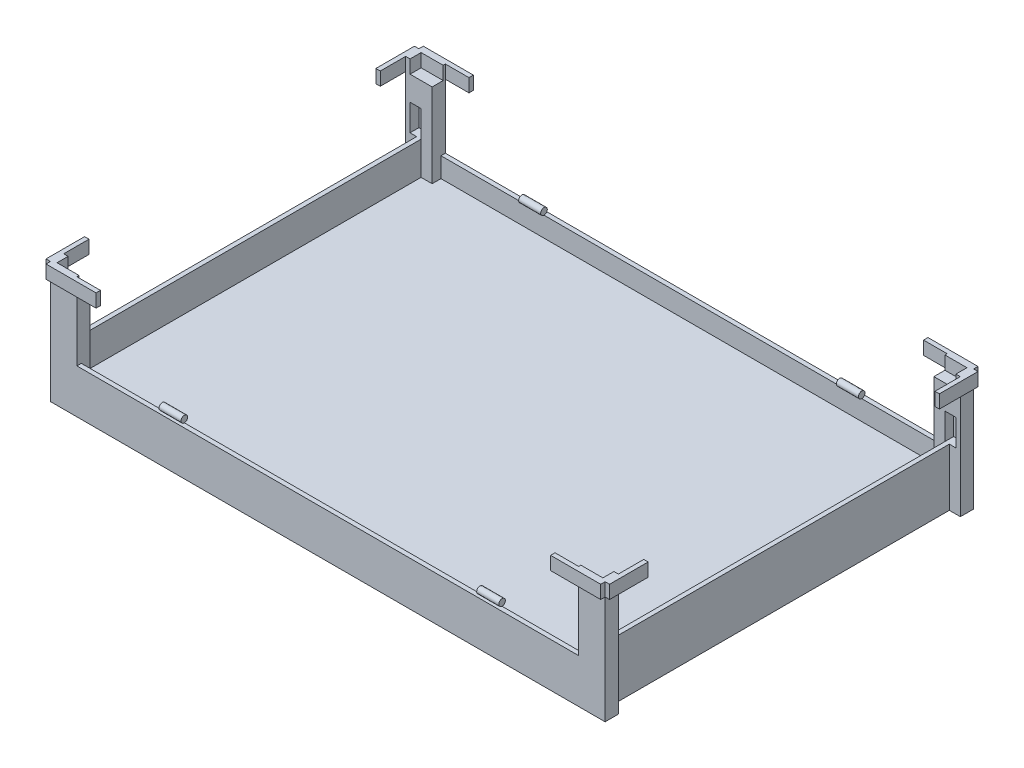
from build123d import *

# Parameters (mm, degrees)
SCHIZZO1_W                    = 1207
SCHIZZO1_H                    = 835
ESTRUSIONE_ESTRUSIONE2_DEPTH  = 100
SVUOTA1_T                     = -10
ESTRUSIONE_ESTRUSIONE3_REACH  = 837
SCHIZZO6_W                    = 1207
SCHIZZO6_H                    = 10
SCHIZZO12_W                   = 10
SCHIZZO12_H                   = 835
ESTRUSIONE_ESTRUSIONE10_DEPTH = 30
SCHIZZO7_W                    = 60
SCHIZZO7_H                    = 275
ESTRUSIONE_ESTRUSIONE4_DEPTH  = 10
SCHIZZO8_W                    = 20
SCHIZZO8_H                    = 145
ESTRUSIONE_ESTRUSIONE5_DEPTH  = 10
SCHIZZO9_W                    = 5
SCHIZZO9_H                    = 30
ESTRUSIONE_ESTRUSIONE6_DEPTH  = 75
SCHIZZO10_W                   = 5
SCHIZZO10_H                   = 30
ESTRUSIONE_ESTRUSIONE7_DEPTH  = 65
SCHIZZO11_W                   = 5
SCHIZZO11_H                   = 20
ESTRUSIONE_ESTRUSIONE8_DEPTH  = 25
SCHIZZO8_3_W                  = 20
SCHIZZO8_3_H                  = 130
ESTRUSIONE_ESTRUSIONE9_DEPTH  = 25
SCHIZZO14_W                   = 87.5
SCHIZZO14_H                   = 30
ESTRUSIONE_ESTRUSIONE12_DEPTH = 10
SCHIZZO15_W                   = 50
SCHIZZO15_H                   = 5
TAGLIO_ESTRUSIONE1_DEPTH      = 30
SCHIZZO16_W                   = 20
SCHIZZO16_H                   = 20
ESTRUSIONE_ESTRUSIONE13_DEPTH = 190
SCHIZZO17_W                   = 30
SCHIZZO17_H                   = 20
ESTRUSIONE_ESTRUSIONE14_DEPTH = 50
SCHIZZO18_W                   = 113.5
SCHIZZO18_H                   = 30
ESTRUSIONE_ESTRUSIONE15_DEPTH = 10
SPECCHIA2_COPY_1_SKETCH_W     = 60
SPECCHIA2_COPY_1_SKETCH_H     = 275
SPECCHIA2_COPY_1_DEPTH        = 10
SPECCHIA2_COPY_2_SKETCH_W     = 20
SPECCHIA2_COPY_2_SKETCH_H     = 145
SPECCHIA2_COPY_2_DEPTH        = 10
SPECCHIA2_COPY_3_SKETCH_W     = 5
SPECCHIA2_COPY_3_SKETCH_H     = 30
SPECCHIA2_COPY_3_DEPTH        = 75
SPECCHIA2_COPY_4_SKETCH_W     = 5
SPECCHIA2_COPY_4_SKETCH_H     = 30
SPECCHIA2_COPY_4_DEPTH        = 65
SPECCHIA2_COPY_5_SKETCH_W     = 5
SPECCHIA2_COPY_5_SKETCH_H     = 20
SPECCHIA2_COPY_5_DEPTH        = 25
SPECCHIA2_COPY_6_SKETCH_W     = 20
SPECCHIA2_COPY_6_SKETCH_H     = 130
SPECCHIA2_COPY_6_DEPTH        = 25
SPECCHIA2_COPY_7_SKETCH_W     = 87.5
SPECCHIA2_COPY_7_SKETCH_H     = 30
SPECCHIA2_COPY_7_DEPTH        = 10
SPECCHIA2_COPY_8_SKETCH_W     = 50
SPECCHIA2_COPY_8_SKETCH_H     = 5
SPECCHIA2_COPY_8_DEPTH        = 30
SPECCHIA2_COPY_9_SKETCH_W     = 20
SPECCHIA2_COPY_9_SKETCH_H     = 20
SPECCHIA2_COPY_9_DEPTH        = 190
SPECCHIA2_COPY_10_SKETCH_W    = 30
SPECCHIA2_COPY_10_SKETCH_H    = 20
SPECCHIA2_COPY_10_DEPTH       = 50
SPECCHIA2_COPY_11_SKETCH_W    = 113.5
SPECCHIA2_COPY_11_SKETCH_H    = 30
SPECCHIA2_COPY_11_DEPTH       = 10
SPECCHIA2_COPY_12_SKETCH_W    = 20
SPECCHIA2_COPY_12_SKETCH_H    = 130
SPECCHIA2_COPY_12_DEPTH       = 25
SPECCHIA2_COPY_13_SKETCH_W    = 87.5
SPECCHIA2_COPY_13_SKETCH_H    = 30
SPECCHIA2_COPY_13_DEPTH       = 10
SPECCHIA2_COPY_14_SKETCH_W    = 50
SPECCHIA2_COPY_14_SKETCH_H    = 5
SPECCHIA2_COPY_14_DEPTH       = 30
SPECCHIA2_COPY_15_SKETCH_W    = 20
SPECCHIA2_COPY_15_SKETCH_H    = 20
SPECCHIA2_COPY_15_DEPTH       = 190
SPECCHIA2_COPY_16_SKETCH_W    = 30
SPECCHIA2_COPY_16_SKETCH_H    = 20
SPECCHIA2_COPY_16_DEPTH       = 50
SPECCHIA2_COPY_17_SKETCH_W    = 113.5
SPECCHIA2_COPY_17_SKETCH_H    = 30
SPECCHIA2_COPY_17_DEPTH       = 10
ESTRUSIONE_ESTRUSIONE11_START = 233.5
SCHIZZO13_R                   = 7.5
ESTRUSIONE_ESTRUSIONE11_DEPTH = 50


with BuildPart() as part:
    # Schizzo1 → Estrusione-Estrusione2 (new body)
    with BuildSketch(Plane(origin=(0, 0, 0), x_dir=(1, 0, 0), z_dir=(0, 1, 0))):
        Rectangle(SCHIZZO1_W, SCHIZZO1_H)
    extrude(amount=ESTRUSIONE_ESTRUSIONE2_DEPTH)

    # Svuota1
    svuota1_openings = [part.faces().sort_by_distance(p)[0] for p in [
        (0, 100, 0),
        (0, 0, 0),
    ]]
    offset(amount=SVUOTA1_T, openings=svuota1_openings, kind=Kind.INTERSECTION)

    # Schizzo6 → Estrusione-Estrusione3 (add, up to next)
    with BuildSketch(Plane.XY.offset(417.5), mode=Mode.PRIVATE) as estrusione_estrusione3_sk1:
        with Locations((0, 50)):
            Rectangle(SCHIZZO6_W, SCHIZZO6_H)
    estrusione_estrusione3_tool1 = extrude(estrusione_estrusione3_sk1.sketch, amount=-ESTRUSIONE_ESTRUSIONE3_REACH, mode=Mode.PRIVATE) - part.part
    add(estrusione_estrusione3_tool1.solids().sort_by_distance((0, 50, 417.5))[0])

    # Schizzo12 → Estrusione-Estrusione10 (add)
    with BuildSketch(Plane(origin=(0, 100, 0), x_dir=(1, 0, 0), z_dir=(0, 1, 0))):
        with Locations((598.5, 0)):
            Rectangle(SCHIZZO12_W, SCHIZZO12_H)
        with Locations((-598.5, 0)):
            Rectangle(SCHIZZO12_W, SCHIZZO12_H)
    extrude(amount=ESTRUSIONE_ESTRUSIONE10_DEPTH)

    # Schizzo7 → Estrusione-Estrusione4 (add)
    with BuildSketch(Plane.XY.offset(417.5)):
        with Locations((598.5, 137.5)):
            Rectangle(SCHIZZO7_W, SCHIZZO7_H)
    estrusione_estrusione4 = extrude(amount=-ESTRUSIONE_ESTRUSIONE4_DEPTH)

    # Schizzo8 → Estrusione-Estrusione5 (add)
    with BuildSketch(Plane(origin=(628.5, 0, 0), x_dir=(0, 0, -1), z_dir=(1, 0, 0))):
        with Locations((-397.5, 202.5)):
            Rectangle(SCHIZZO8_W, SCHIZZO8_H)
    estrusione_estrusione5 = extrude(amount=-ESTRUSIONE_ESTRUSIONE5_DEPTH)

    # Schizzo9 → Estrusione-Estrusione6 (add)
    with BuildSketch(Plane(origin=(0, 130, 0), x_dir=(1, 0, 0), z_dir=(0, 1, 0))):
        with Locations((591, -402.5)):
            Rectangle(SCHIZZO9_W, SCHIZZO9_H)
    estrusione_estrusione6 = extrude(amount=-ESTRUSIONE_ESTRUSIONE6_DEPTH)

    # Schizzo10 → Estrusione-Estrusione7 (add)
    with BuildSketch(Plane(origin=(0, 130, 0), x_dir=(1, 0, 0), z_dir=(0, 1, 0))):
        with Locations((591, -402.5)):
            Rectangle(SCHIZZO10_W, SCHIZZO10_H)
    estrusione_estrusione7 = extrude(amount=ESTRUSIONE_ESTRUSIONE7_DEPTH)

    # Schizzo11 → Estrusione-Estrusione8 (add)
    with BuildSketch(Plane(origin=(593.5, -365, 0), x_dir=(0, 1, 0), z_dir=(-1, 0, 0))):
        with Locations((557.5, -397.5)):
            Rectangle(SCHIZZO11_W, SCHIZZO11_H)
    estrusione_estrusione8 = extrude(amount=-ESTRUSIONE_ESTRUSIONE8_DEPTH)

    # Schizzo8_3 → Estrusione-Estrusione9 (add)
    with BuildSketch(Plane(origin=(628.5, 0, 0), x_dir=(0, 0, -1), z_dir=(1, 0, 0))):
        with Locations((-397.5, 65)):
            Rectangle(SCHIZZO8_3_W, SCHIZZO8_3_H)
    estrusione_estrusione9 = extrude(amount=-ESTRUSIONE_ESTRUSIONE9_DEPTH)

    # Schizzo14 → Estrusione-Estrusione12 (add)
    with BuildSketch(Plane(origin=(628.5, 0, 0), x_dir=(0, 0, -1), z_dir=(1, 0, 0))):
        with Locations((-373.75, 260)):
            Rectangle(SCHIZZO14_W, SCHIZZO14_H)
    estrusione_estrusione12 = extrude(amount=ESTRUSIONE_ESTRUSIONE12_DEPTH)

    # Schizzo15 → Taglio-Estrusione1 (cut)
    with BuildSketch(Plane(origin=(0, 275, 0), x_dir=(1, 0, 0), z_dir=(0, 1, 0))):
        with Locations((593.5, -410)):
            Rectangle(SCHIZZO15_W, SCHIZZO15_H)
    taglio_estrusione1 = extrude(amount=-TAGLIO_ESTRUSIONE1_DEPTH, mode=Mode.SUBTRACT)

    # Schizzo16 → Estrusione-Estrusione13 (add)
    with BuildSketch(Plane(origin=(0, 55, 0), x_dir=(1, 0, 0), z_dir=(0, 1, 0))):
        with Locations((578.5, -397.5)):
            Rectangle(SCHIZZO16_W, SCHIZZO16_H)
    estrusione_estrusione13 = extrude(amount=ESTRUSIONE_ESTRUSIONE13_DEPTH)

    # Schizzo17 → Estrusione-Estrusione14 (add)
    with BuildSketch(Plane(origin=(0, 195, 0), x_dir=(1, 0, 0), z_dir=(0, 1, 0))):
        with Locations((603.5, -397.5)):
            Rectangle(SCHIZZO17_W, SCHIZZO17_H)
    estrusione_estrusione14 = extrude(amount=ESTRUSIONE_ESTRUSIONE14_DEPTH)

    # Schizzo18 → Estrusione-Estrusione15 (add)
    with BuildSketch(Plane.XY.offset(417.5)):
        with Locations((571.75, 260)):
            Rectangle(SCHIZZO18_W, SCHIZZO18_H)
    estrusione_estrusione15 = extrude(amount=ESTRUSIONE_ESTRUSIONE15_DEPTH)

    # Specchia1: Estrusione-Estrusione4, Estrusione-Estrusione5, Estrusione-Estrusione6, Estrusione-Estrusione7, Estrusione-Estrusione8, Estrusione-Estrusione9, Estrusione-Estrusione12, Taglio-Estrusione1, Estrusione-Estrusione13, Estrusione-Estrusione14, Estrusione-Estrusione15 across plane
    add(estrusione_estrusione4.mirror(Plane.XY))
    add(estrusione_estrusione5.mirror(Plane.XY))
    add(estrusione_estrusione6.mirror(Plane.XY))
    add(estrusione_estrusione7.mirror(Plane.XY))
    add(estrusione_estrusione8.mirror(Plane.XY))
    add(estrusione_estrusione9.mirror(Plane.XY))
    add(estrusione_estrusione12.mirror(Plane.XY))
    add(taglio_estrusione1.mirror(Plane.XY), mode=Mode.SUBTRACT)
    add(estrusione_estrusione13.mirror(Plane.XY))
    add(estrusione_estrusione14.mirror(Plane.XY))
    add(estrusione_estrusione15.mirror(Plane.XY))

    # Specchia2: Estrusione-Estrusione4, Estrusione-Estrusione5, Estrusione-Estrusione6, Estrusione-Estrusione7, Estrusione-Estrusione8 across plane
    add(estrusione_estrusione4.mirror(Plane(origin=(0, 0, 0), x_dir=(0, 0, 1), z_dir=(1, 0, 0))))
    add(estrusione_estrusione5.mirror(Plane(origin=(0, 0, 0), x_dir=(0, 0, 1), z_dir=(1, 0, 0))))
    add(estrusione_estrusione6.mirror(Plane(origin=(0, 0, 0), x_dir=(0, 0, 1), z_dir=(1, 0, 0))))
    add(estrusione_estrusione7.mirror(Plane(origin=(0, 0, 0), x_dir=(0, 0, 1), z_dir=(1, 0, 0))))
    add(estrusione_estrusione8.mirror(Plane(origin=(0, 0, 0), x_dir=(0, 0, 1), z_dir=(1, 0, 0))))

    # Specchia2 copy 1 sketch → Specchia2 copy 1 (add)
    with BuildSketch(Plane(origin=(0, 0, -417.5), x_dir=(-1, 0, 0), z_dir=(0, 0, -1))):
        with Locations((598.5, 137.5)):
            Rectangle(SPECCHIA2_COPY_1_SKETCH_W, SPECCHIA2_COPY_1_SKETCH_H)
    extrude(amount=-SPECCHIA2_COPY_1_DEPTH)

    # Specchia2 copy 2 sketch → Specchia2 copy 2 (add)
    with BuildSketch(Plane.ZY.offset(628.5)):
        with Locations((-397.5, 202.5)):
            Rectangle(SPECCHIA2_COPY_2_SKETCH_W, SPECCHIA2_COPY_2_SKETCH_H)
    extrude(amount=-SPECCHIA2_COPY_2_DEPTH)

    # Specchia2 copy 3 sketch → Specchia2 copy 3 (add)
    with BuildSketch(Plane(origin=(0, 130, 0), x_dir=(-1, 0, 0), z_dir=(0, 1, 0))):
        with Locations((591, -402.5)):
            Rectangle(SPECCHIA2_COPY_3_SKETCH_W, SPECCHIA2_COPY_3_SKETCH_H)
    extrude(amount=-SPECCHIA2_COPY_3_DEPTH)

    # Specchia2 copy 4 sketch → Specchia2 copy 4 (add)
    with BuildSketch(Plane(origin=(0, 130, 0), x_dir=(-1, 0, 0), z_dir=(0, 1, 0))):
        with Locations((591, -402.5)):
            Rectangle(SPECCHIA2_COPY_4_SKETCH_W, SPECCHIA2_COPY_4_SKETCH_H)
    extrude(amount=SPECCHIA2_COPY_4_DEPTH)

    # Specchia2 copy 5 sketch → Specchia2 copy 5 (add)
    with BuildSketch(Plane(origin=(-593.5, -365, 0), x_dir=(0, 1, 0), z_dir=(1, 0, 0))):
        with Locations((557.5, -397.5)):
            Rectangle(SPECCHIA2_COPY_5_SKETCH_W, SPECCHIA2_COPY_5_SKETCH_H)
    extrude(amount=-SPECCHIA2_COPY_5_DEPTH)

    # Specchia2 copy 6 sketch → Specchia2 copy 6 (add)
    with BuildSketch(Plane.ZY.offset(628.5)):
        with Locations((-397.5, 65)):
            Rectangle(SPECCHIA2_COPY_6_SKETCH_W, SPECCHIA2_COPY_6_SKETCH_H)
    extrude(amount=-SPECCHIA2_COPY_6_DEPTH)

    # Specchia2 copy 7 sketch → Specchia2 copy 7 (add)
    with BuildSketch(Plane.ZY.offset(628.5)):
        with Locations((-373.75, 260)):
            Rectangle(SPECCHIA2_COPY_7_SKETCH_W, SPECCHIA2_COPY_7_SKETCH_H)
    extrude(amount=SPECCHIA2_COPY_7_DEPTH)

    # Specchia2 copy 8 sketch → Specchia2 copy 8 (cut)
    with BuildSketch(Plane(origin=(0, 275, 0), x_dir=(-1, 0, 0), z_dir=(0, 1, 0))):
        with Locations((593.5, -410)):
            Rectangle(SPECCHIA2_COPY_8_SKETCH_W, SPECCHIA2_COPY_8_SKETCH_H)
    extrude(amount=-SPECCHIA2_COPY_8_DEPTH, mode=Mode.SUBTRACT)

    # Specchia2 copy 9 sketch → Specchia2 copy 9 (add)
    with BuildSketch(Plane(origin=(0, 55, 0), x_dir=(-1, 0, 0), z_dir=(0, 1, 0))):
        with Locations((578.5, -397.5)):
            Rectangle(SPECCHIA2_COPY_9_SKETCH_W, SPECCHIA2_COPY_9_SKETCH_H)
    extrude(amount=SPECCHIA2_COPY_9_DEPTH)

    # Specchia2 copy 10 sketch → Specchia2 copy 10 (add)
    with BuildSketch(Plane(origin=(0, 195, 0), x_dir=(-1, 0, 0), z_dir=(0, 1, 0))):
        with Locations((603.5, -397.5)):
            Rectangle(SPECCHIA2_COPY_10_SKETCH_W, SPECCHIA2_COPY_10_SKETCH_H)
    extrude(amount=SPECCHIA2_COPY_10_DEPTH)

    # Specchia2 copy 11 sketch → Specchia2 copy 11 (add)
    with BuildSketch(Plane(origin=(0, 0, -417.5), x_dir=(-1, 0, 0), z_dir=(0, 0, -1))):
        with Locations((571.75, 260)):
            Rectangle(SPECCHIA2_COPY_11_SKETCH_W, SPECCHIA2_COPY_11_SKETCH_H)
    extrude(amount=SPECCHIA2_COPY_11_DEPTH)

    # Specchia2 copy 12 sketch → Specchia2 copy 12 (add)
    with BuildSketch(Plane(origin=(-628.5, 0, 0), x_dir=(0, 0, -1), z_dir=(-1, 0, 0))):
        with Locations((-397.5, -65)):
            Rectangle(SPECCHIA2_COPY_12_SKETCH_W, SPECCHIA2_COPY_12_SKETCH_H)
    extrude(amount=-SPECCHIA2_COPY_12_DEPTH)

    # Specchia2 copy 13 sketch → Specchia2 copy 13 (add)
    with BuildSketch(Plane(origin=(-628.5, 0, 0), x_dir=(0, 0, -1), z_dir=(-1, 0, 0))):
        with Locations((-373.75, -260)):
            Rectangle(SPECCHIA2_COPY_13_SKETCH_W, SPECCHIA2_COPY_13_SKETCH_H)
    extrude(amount=SPECCHIA2_COPY_13_DEPTH)

    # Specchia2 copy 14 sketch → Specchia2 copy 14 (cut)
    with BuildSketch(Plane(origin=(0, 275, 0), x_dir=(-1, 0, 0), z_dir=(0, 1, 0))):
        with Locations((593.5, 410)):
            Rectangle(SPECCHIA2_COPY_14_SKETCH_W, SPECCHIA2_COPY_14_SKETCH_H)
    extrude(amount=-SPECCHIA2_COPY_14_DEPTH, mode=Mode.SUBTRACT)

    # Specchia2 copy 15 sketch → Specchia2 copy 15 (add)
    with BuildSketch(Plane(origin=(0, 55, 0), x_dir=(-1, 0, 0), z_dir=(0, 1, 0))):
        with Locations((578.5, 397.5)):
            Rectangle(SPECCHIA2_COPY_15_SKETCH_W, SPECCHIA2_COPY_15_SKETCH_H)
    extrude(amount=SPECCHIA2_COPY_15_DEPTH)

    # Specchia2 copy 16 sketch → Specchia2 copy 16 (add)
    with BuildSketch(Plane(origin=(0, 195, 0), x_dir=(-1, 0, 0), z_dir=(0, 1, 0))):
        with Locations((603.5, 397.5)):
            Rectangle(SPECCHIA2_COPY_16_SKETCH_W, SPECCHIA2_COPY_16_SKETCH_H)
    extrude(amount=SPECCHIA2_COPY_16_DEPTH)

    # Specchia2 copy 17 sketch → Specchia2 copy 17 (add)
    with BuildSketch(Plane(origin=(0, 0, 417.5), x_dir=(-1, 0, 0), z_dir=(0, 0, 1))):
        with Locations((571.75, -260)):
            Rectangle(SPECCHIA2_COPY_17_SKETCH_W, SPECCHIA2_COPY_17_SKETCH_H)
    extrude(amount=SPECCHIA2_COPY_17_DEPTH)


with BuildPart() as body_2:
    # Schizzo13 → Estrusione-Estrusione11 (new body)
    with BuildSketch(Plane.ZY.offset(-568.5).offset(ESTRUSIONE_ESTRUSIONE11_START)):
        with Locations((-407.5, 107.5)):
            Circle(SCHIZZO13_R)
    extrude(amount=-ESTRUSIONE_ESTRUSIONE11_DEPTH)


with BuildPart() as body_3:
    # Specchia3: mirrored copy
    add(body_2.part.mirror(Plane(origin=(0, 0, 0), x_dir=(0, 0, 1), z_dir=(1, 0, 0))))


with BuildPart() as body_4:
    # Specchia4: mirrored copy
    add(body_3.part.mirror(Plane.XY))


with BuildPart() as body_5:
    # Specchia4 2: mirrored copy
    add(body_2.part.mirror(Plane.XY))


solid = Compound([part.part, body_2.part, body_3.part, body_4.part, body_5.part])
